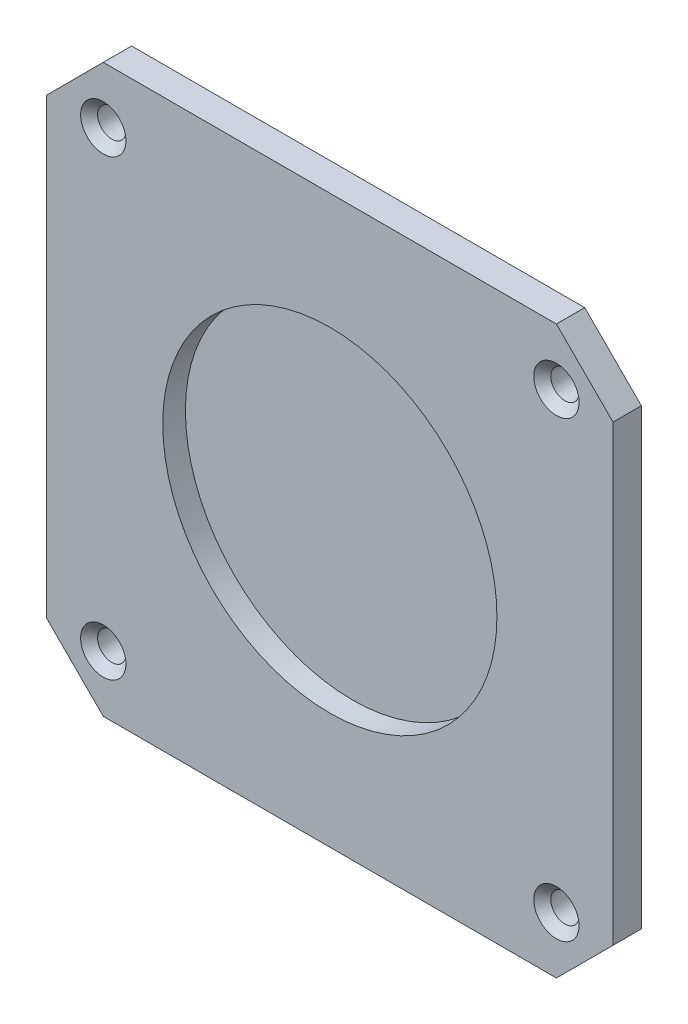
from build123d import *

# Parameters (mm, degrees)
BOSS_EXTRUDE1_DEPTH           = 5
CIRCLE_R                      = 29.5
CUT_EXTRUDE1_DEPTH            = 4
CSK_FOR_M4_SFHCS1_D           = 5
CSK_FOR_M4_SFHCS1_CSINK_D     = 8
CSK_FOR_M4_SFHCS1_CSINK_ANGLE = 90


with BuildPart() as part:
    # base → Boss-Extrude1 (new body)
    with BuildSketch(Plane.XY):
        Polygon((0, 10), (0, 90), (10, 100), (90, 100), (100, 90), (100, 10), (90, 0), (10, 0), align=None)
    extrude(amount=BOSS_EXTRUDE1_DEPTH)

    # circle → Cut-Extrude1 (cut)
    with BuildSketch(Plane.XY.offset(5)):
        with Locations((50, 50)):
            Circle(CIRCLE_R)
    extrude(amount=-CUT_EXTRUDE1_DEPTH, mode=Mode.SUBTRACT)

    # CSK for M4 SFHCS1 (through all)
    with Locations(Plane.XY.offset(5)):
        with Locations((90, 90), (10, 90), (10, 10), (90, 10)):
            CounterSinkHole(CSK_FOR_M4_SFHCS1_D / 2, CSK_FOR_M4_SFHCS1_CSINK_D / 2, counter_sink_angle=CSK_FOR_M4_SFHCS1_CSINK_ANGLE)


solid = part.part
